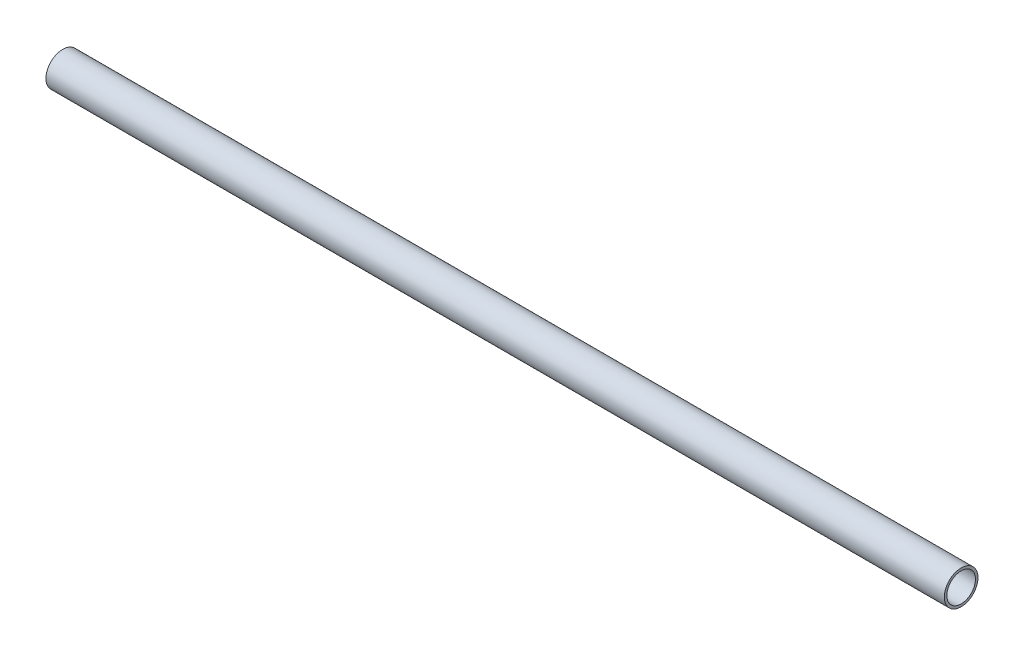
from build123d import *

# Parameters (mm, degrees)
SKETCH1_R           = 4.7625
SKETCH1_R_2         = 4.0513
BOSS_EXTRUDE1_DEPTH = 127
SKETCH2_R           = 3.175
CUT_EXTRUDE1_DEPTH  = 5.7625


with BuildPart() as part:
    # Sketch1 → Boss-Extrude1 (new body, symmetric)
    with BuildSketch(Plane(origin=(0, 0, 0), x_dir=(0, 0, -1), z_dir=(1, 0, 0))):
        Circle(SKETCH1_R)
        Circle(SKETCH1_R_2, mode=Mode.SUBTRACT)
    extrude(amount=BOSS_EXTRUDE1_DEPTH, both=True)

    # Sketch2 → Cut-Extrude1 (cut, through all)
    with BuildSketch(Plane(origin=(0, 0, 0), x_dir=(1, 0, 0), z_dir=(0, 1, 0))):
        with Locations((-112.5, 0)):
            Circle(SKETCH2_R)
        with Locations((-37.5, 0)):
            Circle(SKETCH2_R)
        with Locations((37.5, 0)):
            Circle(SKETCH2_R)
        with Locations((112.5, 0)):
            Circle(SKETCH2_R)
    extrude(amount=-CUT_EXTRUDE1_DEPTH, mode=Mode.SUBTRACT)


solid = part.part
